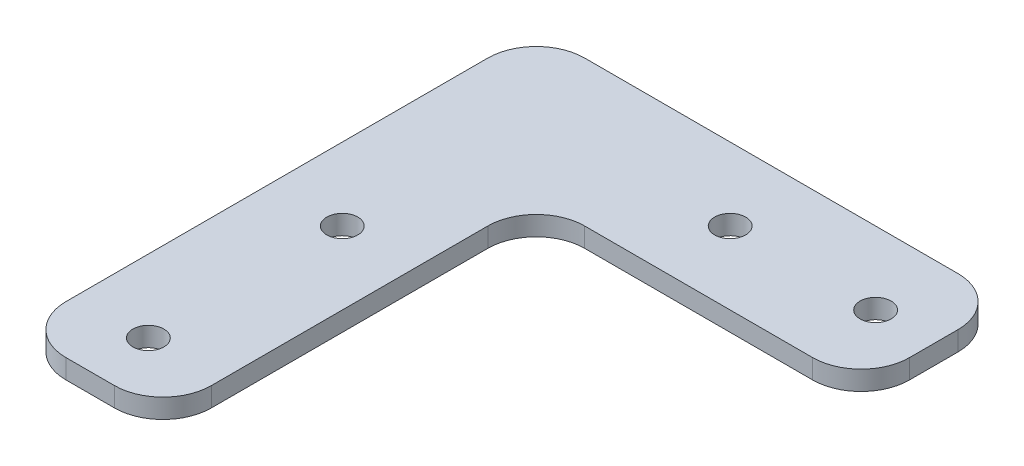
from build123d import *

# Parameters (mm, degrees)
SKETCH1_R           = 1.6
BOSS_EXTRUDE1_DEPTH = 2
FILLET1_R           = 5


with BuildPart() as part:
    # Sketch1 → Boss-Extrude1 (new body)
    with BuildSketch(Plane(origin=(0, 0, 0), x_dir=(1, 0, 0), z_dir=(0, 1, 0))):
        Polygon((7.5, -7.5), (7.5, -46), (-7.5, -46), (-7.5, 7.5), (41, 7.5), (41, -7.5), align=None)
        with Locations((0, -40)):
            Circle(SKETCH1_R, mode=Mode.SUBTRACT)
        with Locations((0, -20)):
            Circle(SKETCH1_R, mode=Mode.SUBTRACT)
        with Locations((20, 0)):
            Circle(SKETCH1_R, mode=Mode.SUBTRACT)
        with Locations((35, 0)):
            Circle(SKETCH1_R, mode=Mode.SUBTRACT)
    extrude(amount=BOSS_EXTRUDE1_DEPTH)

    # Fillet1
    fillet1_edges = [part.edges().sort_by_distance(p)[0] for p in [
        (7.5, 1, 7.5),
        (7.5, 1, 46),
        (-7.5, 1, 46),
        (-7.5, 1, -7.5),
        (41, 1, -7.5),
        (41, 1, 7.5),
    ]]
    fillet(fillet1_edges, radius=FILLET1_R)


solid = part.part
